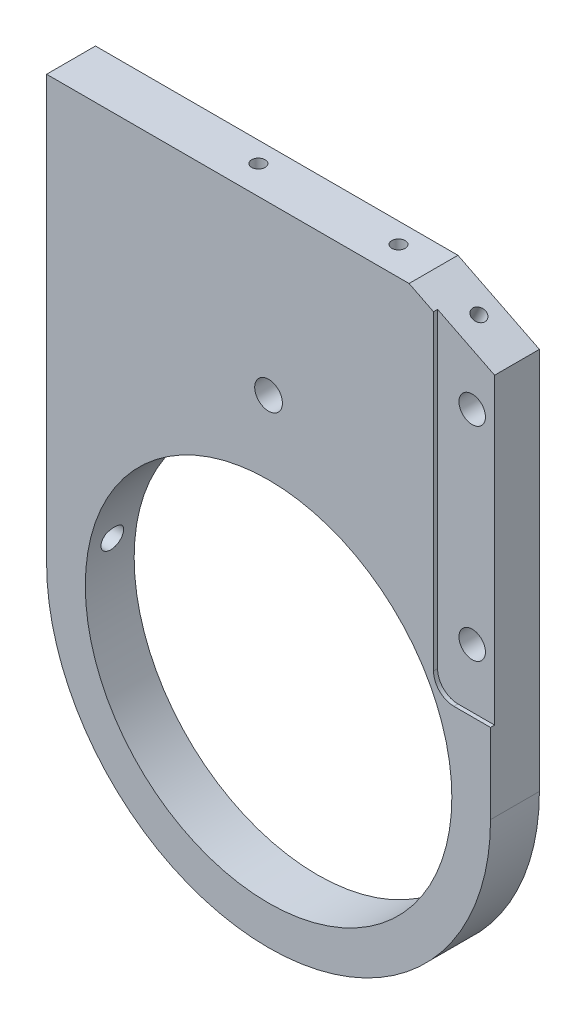
from build123d import *

# Parameters (mm, degrees)
CROQUIS1_R                    = 45
SALIENTE_EXTRUIR1_DEPTH       = 6
TALADRO_ROSCADO_M41_D         = 3.3
TALADRO_ROSCADO_M41_DEPTH     = 20
TALADRO_ROSCADO_M41_TIP       = 0.991420021
TALADRO_ROSCADO_M42_D         = 3.3
TALADRO_ROSCADO_M42_DEPTH     = 20
TALADRO_ROSCADO_M42_TIP       = 0.991420021
CORTAR_EXTRUIR1_DEPTH         = 1
CROQUIS7_R                    = 3.25
CORTAR_EXTRUIR2_DEPTH         = 37.7
CROQUIS8_R                    = 5
CORTAR_EXTRUIR3_DEPTH         = 6
TALADRO_ROSCADO_M6X0_51_D     = 5.5
TALADRO_ROSCADO_M6X0_51_DEPTH = 22.5
TALADRO_ROSCADO_M6X0_51_TIP   = 1.652366702
TALADRO_ROSCADO_M6X0_52_D     = 5.5
TALADRO_ROSCADO_M6X0_52_DEPTH = 10.5
TALADRO_ROSCADO_M6X0_52_TIP   = 1.652366702
TALADRO_ROSCADO_M81_D         = 6.8


with BuildPart() as part:
    # Croquis1 → Saliente-Extruir1 (new body, symmetric)
    with BuildSketch(Plane.XY):
        with BuildLine():
            Line((-54.5, 0), (-54.5, 104))
            Line((-54.5, 104), (34.5, 104))
            Line((34.5, 104), (54.5, 94))
            Line((54.5, 94), (54.5, 0))
            ThreePointArc((54.5, 0), (0, -54.5), (-54.5, 0))
        make_face()
        Circle(CROQUIS1_R, mode=Mode.SUBTRACT)
    extrude(amount=SALIENTE_EXTRUIR1_DEPTH, both=True)

    # Taladro roscado M41
    with Locations(Plane(origin=(48.5, 97, 0), x_dir=(-0.894427191, 0.447213595, 0), z_dir=(0.447213595, 0.894427191, 0))):
        with Locations((4.291796068, -1)):
            Hole(TALADRO_ROSCADO_M41_D / 2, depth=TALADRO_ROSCADO_M41_DEPTH)
            with Locations((0, 0, -(TALADRO_ROSCADO_M41_DEPTH + TALADRO_ROSCADO_M41_TIP / 2))):  # 118° drill point
                Cone(0, TALADRO_ROSCADO_M41_D / 2, TALADRO_ROSCADO_M41_TIP, mode=Mode.SUBTRACT)

    # Taladro roscado M42
    with Locations(Plane(origin=(0, 104, 0), x_dir=(-1, 0, 0), z_dir=(0, 1, 0))):
        with Locations((9.5, -1), (-24.9, -1)):
            Hole(TALADRO_ROSCADO_M42_D / 2, depth=TALADRO_ROSCADO_M42_DEPTH)
            with Locations((0, 0, -(TALADRO_ROSCADO_M42_DEPTH + TALADRO_ROSCADO_M42_TIP / 2))):  # 118° drill point
                Cone(0, TALADRO_ROSCADO_M42_D / 2, TALADRO_ROSCADO_M42_TIP, mode=Mode.SUBTRACT)

    # Croquis6 → Cortar-Extruir1 (cut)
    with BuildSketch(Plane.XY.offset(6)):
        with BuildLine():
            Line((40.5, 104), (65.659367038, 104))
            Line((65.659367038, 104), (65.659367038, 19.6))
            Line((65.659367038, 19.6), (45.5, 19.6))
            ThreePointArc((45.5, 19.6), (41.964466094, 21.064466094), (40.5, 24.6))
            Line((40.5, 24.6), (40.5, 104))
        make_face()
    extrude(amount=-CORTAR_EXTRUIR1_DEPTH, mode=Mode.SUBTRACT)

    # Croquis7 → Cortar-Extruir2 (cut)
    with BuildSketch(Plane.XY.offset(5)):
        with Locations((49, 84)):
            Circle(CROQUIS7_R)
        with Locations((49, 34)):
            Circle(CROQUIS7_R)
    extrude(amount=-CORTAR_EXTRUIR2_DEPTH, mode=Mode.SUBTRACT)

    # Croquis8 → Cortar-Extruir3 (cut)
    with BuildSketch(Plane(origin=(0, 0, -6), x_dir=(-1, 0, 0), z_dir=(0, 0, -1))):
        with Locations((-49, 84)):
            Circle(CROQUIS8_R)
        with Locations((-49, 34)):
            Circle(CROQUIS8_R)
    extrude(amount=-CORTAR_EXTRUIR3_DEPTH, mode=Mode.SUBTRACT)

    # Taladro roscado M6x0.51
    with Locations(Plane.ZY.offset(54.5)):
        with Locations((0, 96.5), (0, 51.7)):
            Hole(TALADRO_ROSCADO_M6X0_51_D / 2, depth=TALADRO_ROSCADO_M6X0_51_DEPTH)
            with Locations((0, 0, -(TALADRO_ROSCADO_M6X0_51_DEPTH + TALADRO_ROSCADO_M6X0_51_TIP / 2))):  # 118° drill point
                Cone(0, TALADRO_ROSCADO_M6X0_51_D / 2, TALADRO_ROSCADO_M6X0_51_TIP, mode=Mode.SUBTRACT)

    # Taladro roscado M6x0.52
    with Locations(Plane.ZY.offset(54.5)):
        with Locations((0, 7.5)):
            Hole(TALADRO_ROSCADO_M6X0_52_D / 2, depth=TALADRO_ROSCADO_M6X0_52_DEPTH)
            with Locations((0, 0, -(TALADRO_ROSCADO_M6X0_52_DEPTH + TALADRO_ROSCADO_M6X0_52_TIP / 2))):  # 118° drill point
                Cone(0, TALADRO_ROSCADO_M6X0_52_D / 2, TALADRO_ROSCADO_M6X0_52_TIP, mode=Mode.SUBTRACT)

    # Taladro roscado M81 (through all)
    with Locations(Plane.XY.offset(6)):
        with Locations((0, 63)):
            Hole(TALADRO_ROSCADO_M81_D / 2)


solid = part.part
